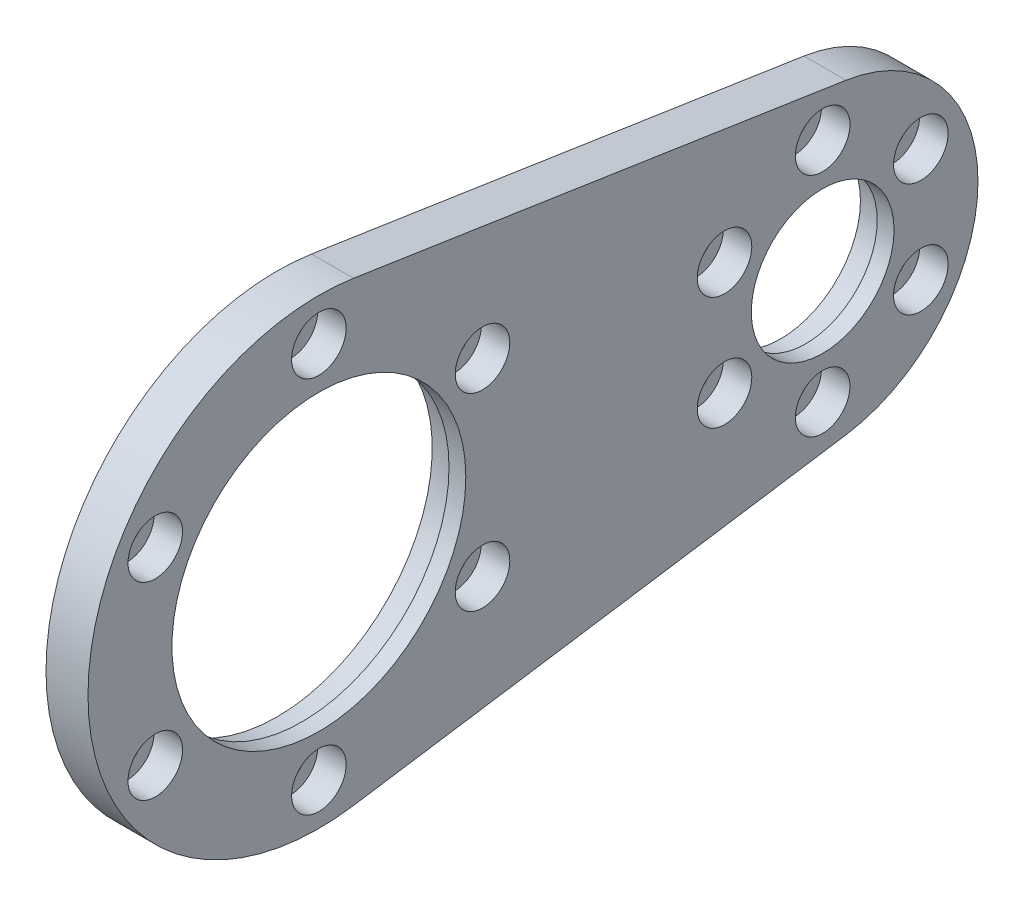
from build123d import *

# Parameters (mm, degrees)
SKETCH_3_R                   = 27.5
EXTRUDE_1_DEPTH              = 2
SKETCH_4_R                   = 27.5
SKETCH_4_R_2                 = 17.5
EXTRUDE_2_DEPTH              = 1
SKETCH_5_R                   = 27.5
SKETCH_5_R_2                 = 18.5
EXTRUDE_3_DEPTH              = 7
SKETCH_6_R                   = 27.5
SKETCH_6_R_2                 = 17.5
EXTRUDE_4_DEPTH              = 2
EXTRUDE_5_DEPTH              = 9
SKETCH_11_R                  = 8.5
CUT_EXTRUDE_3_DEPTH          = 111
SKETCH_12_R                  = 9.5
CUT_EXTRUDE_4_DEPTH          = 2.5
SKETCH_13_R                  = 9.5
EXTRUDE_6_DEPTH              = 5
HOLE_WIZARD_M3_4_D           = 3.4
HOLE_WIZARD_M3_4_CBORE_D     = 6.5
HOLE_WIZARD_M3_4_CBORE_DEPTH = 3.4
PATTERN_CIRCULAR_1_COUNT     = 3
SKETCH_17_W                  = 25.034739103
SKETCH_17_H                  = 64.604217311
CUT_EXTRUDE_5_DEPTH          = 1111
HOLE_WIZARD_M3_2_D           = 3.2
HOLE_WIZARD_M3_2_CBORE_D     = 6.5
HOLE_WIZARD_M3_2_CBORE_DEPTH = 3.4
PATTERN_CIRCULAR_2_COUNT     = 6
HOLE_WIZARD_M3_3_D           = 3.2
HOLE_WIZARD_M3_3_CBORE_D     = 6.5
HOLE_WIZARD_M3_3_CBORE_DEPTH = 3.4
PATTERN_CIRCULAR_3_COUNT     = 6


with BuildPart() as part:
    # 스케치3 → 보스-돌출1 (new body)
    with BuildSketch(Plane(origin=(0, 0, 0), x_dir=(0, 0, -1), z_dir=(1, 0, 0))):
        Circle(SKETCH_3_R)
    extrude(amount=EXTRUDE_1_DEPTH)

    # 스케치4 → 보스-돌출2 (add)
    with BuildSketch(Plane(origin=(2, 0, 0), x_dir=(0, 0, -1), z_dir=(1, 0, 0))):
        Circle(SKETCH_4_R)
        Circle(SKETCH_4_R_2, mode=Mode.SUBTRACT)
    extrude(amount=EXTRUDE_2_DEPTH)

    # 스케치5 → 보스-돌출3 (add)
    with BuildSketch(Plane(origin=(3, 0, 0), x_dir=(0, 0, -1), z_dir=(1, 0, 0))):
        Circle(SKETCH_5_R)
        Circle(SKETCH_5_R_2, mode=Mode.SUBTRACT)
    extrude(amount=EXTRUDE_3_DEPTH)

    # 스케치6 → 보스-돌출4 (add)
    with BuildSketch(Plane(origin=(10, 0, 0), x_dir=(0, 0, -1), z_dir=(1, 0, 0))):
        Circle(SKETCH_6_R)
        Circle(SKETCH_6_R_2, mode=Mode.SUBTRACT)
    extrude(amount=EXTRUDE_4_DEPTH)

    # 스케치10 → 보스-돌출5 (add)
    with BuildSketch(Plane(origin=(12, 0, 0), x_dir=(0, 0, -1), z_dir=(1, 0, 0))):
        with BuildLine():
            Line((4.125, 27.188864908), (62.775, 18.290690938))
            ThreePointArc((62.775, 18.290690938), (78.5, 0), (62.775, -18.290690938))
            Line((62.775, -18.290690938), (4.125, -27.188864908))
            ThreePointArc((4.125, -27.188864908), (27.5, 0), (4.125, 27.188864908))
        make_face()
    extrude(amount=-EXTRUDE_5_DEPTH)

    # 스케치11 → 컷-돌출3 (cut, symmetric)
    with BuildSketch(Plane(origin=(7.5, 0, 0), x_dir=(0, 0, -1), z_dir=(1, 0, 0))):
        with Locations((60, 0)):
            Circle(SKETCH_11_R)
    extrude(amount=CUT_EXTRUDE_3_DEPTH, both=True, mode=Mode.SUBTRACT)

    # 스케치12 → 컷-돌출4 (cut, symmetric)
    with BuildSketch(Plane(origin=(7.5, 0, 0), x_dir=(0, 0, -1), z_dir=(1, 0, 0))):
        with Locations((60, 0)):
            Circle(SKETCH_12_R)
    extrude(amount=CUT_EXTRUDE_4_DEPTH, both=True, mode=Mode.SUBTRACT)

    # 스케치13 → 보스-돌출6 (add)
    with BuildSketch(Plane.ZY):
        Circle(SKETCH_13_R)
    extrude(amount=EXTRUDE_6_DEPTH)

    # M3 육각 소켓 머리 캡 나사용 카운터보어4 (through all)
    with Locations(Plane(origin=(2, 0, 0), x_dir=(0, 0, -1), z_dir=(1, 0, 0))):
        with Locations((0, 5)):
            hole_wizard_m3_4 = CounterBoreHole(HOLE_WIZARD_M3_4_D / 2, HOLE_WIZARD_M3_4_CBORE_D / 2, HOLE_WIZARD_M3_4_CBORE_DEPTH)

    # 원형 패턴1: M3 육각 소켓 머리 캡 나사용 카운터보어4 ×3 about axis
    pattern_circular_1_axis = Axis((0, 0, 0), (1, 0, 0))
    for i in range(1, PATTERN_CIRCULAR_1_COUNT):
        add(hole_wizard_m3_4.rotate(pattern_circular_1_axis, i * 360 / PATTERN_CIRCULAR_1_COUNT), mode=Mode.SUBTRACT)

    # 스케치17 → 컷-돌출5 (cut, symmetric)
    with BuildSketch(Plane.XY):
        with Locations((-5.517369551, -1.852450676)):
            Rectangle(SKETCH_17_W, SKETCH_17_H)
    extrude(amount=CUT_EXTRUDE_5_DEPTH, both=True, mode=Mode.SUBTRACT)

    # M3 육각 소켓 머리 캡 나사용 카운터보어2 (through all)
    with Locations(Plane(origin=(12, 0, 0), x_dir=(0, 0, -1), z_dir=(1, 0, 0))):
        with Locations((0, 22.5)):
            hole_wizard_m3_2 = CounterBoreHole(HOLE_WIZARD_M3_2_D / 2, HOLE_WIZARD_M3_2_CBORE_D / 2, HOLE_WIZARD_M3_2_CBORE_DEPTH)

    # 원형 패턴2: M3 육각 소켓 머리 캡 나사용 카운터보어2 ×6 about axis
    pattern_circular_2_axis = Axis((0, 0, 0), (1, 0, 0))
    for i in range(1, PATTERN_CIRCULAR_2_COUNT):
        add(hole_wizard_m3_2.rotate(pattern_circular_2_axis, i * 360 / PATTERN_CIRCULAR_2_COUNT), mode=Mode.SUBTRACT)

    # M3 육각 소켓 머리 캡 나사용 카운터보어3 (through all)
    with Locations(Plane(origin=(12, 0, 0), x_dir=(0, 0, -1), z_dir=(1, 0, 0))):
        with Locations((60, 13.5)):
            hole_wizard_m3_3 = CounterBoreHole(HOLE_WIZARD_M3_3_D / 2, HOLE_WIZARD_M3_3_CBORE_D / 2, HOLE_WIZARD_M3_3_CBORE_DEPTH)

    # 원형 패턴3: M3 육각 소켓 머리 캡 나사용 카운터보어3 ×6 about axis
    pattern_circular_3_axis = Axis((0, 0, -60), (1, 0, 0))
    for i in range(1, PATTERN_CIRCULAR_3_COUNT):
        add(hole_wizard_m3_3.rotate(pattern_circular_3_axis, i * 360 / PATTERN_CIRCULAR_3_COUNT), mode=Mode.SUBTRACT)


solid = part.part
